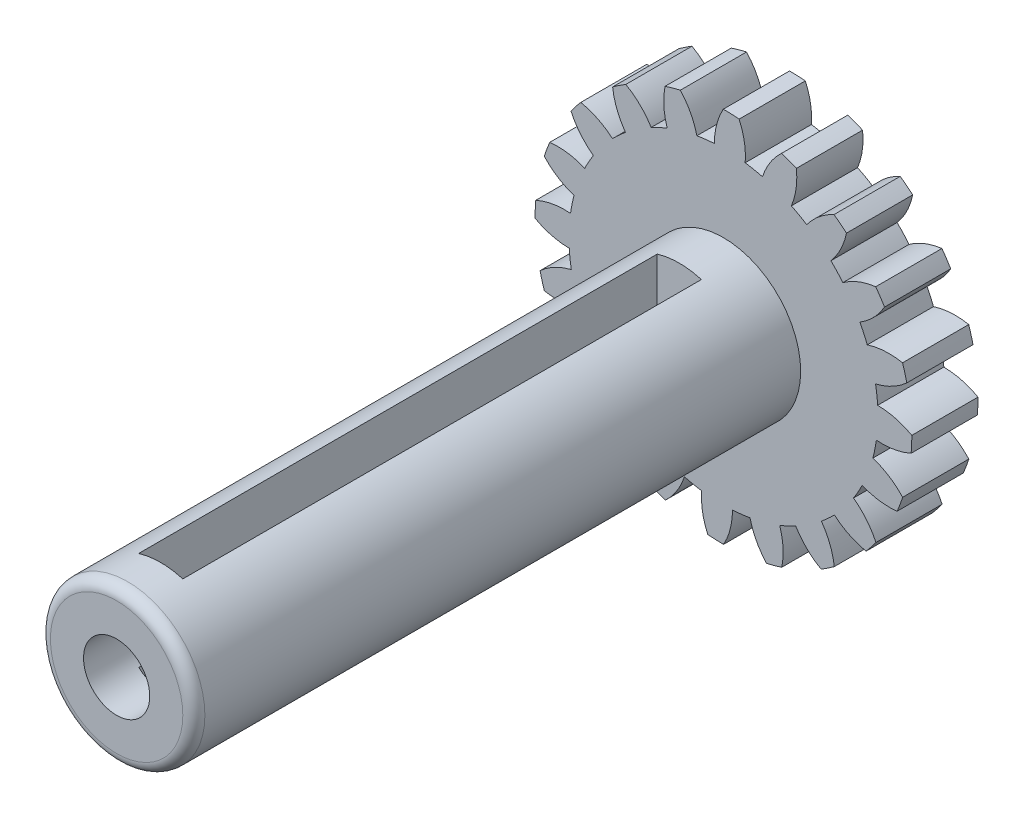
from build123d import *

# Parameters (mm, degrees)
EXTRUDE_4_DEPTH     = 3
SKETCH_5_R          = 3.5
EXTRUDE_6_DEPTH     = 27.5
SKETCH_8_R          = 1.5
CUT_EXTRUDE_1_DEPTH = 10
SKETCH_10_W         = 2
SKETCH_10_H         = 23.5
CUT_EXTRUDE_2_DEPTH = 5
FILLET_1_R          = 0.5


with BuildPart() as part:
    # 草图4 → 凸台-拉伸4 (new body)
    with BuildSketch(Plane.XY):
        with BuildLine():
            ThreePointArc((8.536063079, 0.007574004), (7.787120491, 0.307636704), (6.986931627, 0.410837493))
            ThreePointArc((6.986931627, 0.410837493), (6.952112765, 0.808782481), (6.894647301, 1.204092849))
            ThreePointArc((6.894647301, 1.204092849), (7.649774364, 1.488233206), (8.309831075, 1.95221355))
            ThreePointArc((8.309831075, 1.95221355), (8.220185959, 2.300646222), (8.115937918, 2.644991862))
            ThreePointArc((8.115937918, 2.644991862), (7.310926717, 2.698932461), (6.518011085, 2.549810286))
            ThreePointArc((6.518011085, 2.549810286), (6.361924616, 2.91751884), (6.18511409, 3.275723537))
            ThreePointArc((6.18511409, 3.275723537), (6.815478405, 3.77930417), (7.29985183, 4.424544441))
            ThreePointArc((7.29985183, 4.424544441), (7.106922641, 4.72822174), (6.901368208, 5.023499488))
            ThreePointArc((6.901368208, 5.023499488), (6.119088497, 4.826037904), (5.411062205, 4.439189883))
            ThreePointArc((5.411062205, 4.439189883), (5.148986959, 4.740668128), (4.870138818, 5.026703581))
            ThreePointArc((4.870138818, 5.026703581), (5.314035933, 5.70043051), (5.575312226, 6.463770094))
            ThreePointArc((5.575312226, 6.463770094), (5.297984218, 6.69296597), (5.011244492, 6.910271984))
            ThreePointArc((5.011244492, 6.910271984), (4.328271261, 6.480737132), (3.774440855, 5.894030644))
            ThreePointArc((3.774440855, 5.894030644), (3.432030584, 6.099767788), (3.078440426, 6.285634856))
            ThreePointArc((3.078440426, 6.285634856), (3.292418599, 7.063558994), (3.305022217, 7.870276894))
            ThreePointArc((3.305022217, 7.870276894), (2.970442186, 8.002556058), (2.63058525, 8.12061891))
            ThreePointArc((2.63058525, 8.12061891), (2.113772678, 7.501056656), (1.768350936, 6.77192262))
            ThreePointArc((1.768350936, 6.77192262), (1.379123142, 6.861779679), (0.985402836, 6.929284397))
            ThreePointArc((0.985402836, 6.929284397), (0.948516393, 7.735257109), (0.711213605, 8.506386157))
            ThreePointArc((0.711213605, 8.506386157), (0.352132577, 8.528800203), (-0.007574004, 8.536063079))
            ThreePointArc((-0.007574004, 8.536063079), (-0.307636703, 7.787120491), (-0.410837493, 6.986931627))
            ThreePointArc((-0.410837493, 6.986931627), (-0.808782481, 6.952112765), (-1.204092849, 6.894647301))
            ThreePointArc((-1.204092849, 6.894647301), (-1.488233206, 7.649774364), (-1.95221355, 8.309831075))
            ThreePointArc((-1.95221355, 8.309831075), (-2.300646222, 8.220185959), (-2.644991862, 8.115937918))
            ThreePointArc((-2.644991862, 8.115937918), (-2.698932461, 7.310926717), (-2.549810286, 6.518011085))
            ThreePointArc((-2.549810286, 6.518011085), (-2.91751884, 6.361924616), (-3.275723537, 6.18511409))
            ThreePointArc((-3.275723537, 6.18511409), (-3.77930417, 6.815478405), (-4.424544441, 7.29985183))
            ThreePointArc((-4.424544441, 7.29985183), (-4.72822174, 7.106922641), (-5.023499488, 6.901368208))
            ThreePointArc((-5.023499488, 6.901368208), (-4.826037904, 6.119088497), (-4.439189882, 5.411062205))
            ThreePointArc((-4.439189882, 5.411062205), (-4.740668128, 5.148986959), (-5.026703581, 4.870138818))
            ThreePointArc((-5.026703581, 4.870138818), (-5.70043051, 5.314035933), (-6.463770094, 5.575312226))
            ThreePointArc((-6.463770094, 5.575312226), (-6.69296597, 5.297984218), (-6.910271984, 5.011244492))
            ThreePointArc((-6.910271984, 5.011244492), (-6.480737132, 4.328271262), (-5.894030644, 3.774440855))
            ThreePointArc((-5.894030644, 3.774440855), (-6.099767788, 3.432030584), (-6.285634856, 3.078440426))
            ThreePointArc((-6.285634856, 3.078440426), (-7.063558994, 3.292418599), (-7.870276894, 3.305022217))
            ThreePointArc((-7.870276894, 3.305022217), (-8.002556058, 2.970442186), (-8.12061891, 2.63058525))
            ThreePointArc((-8.12061891, 2.63058525), (-7.501056656, 2.113772678), (-6.77192262, 1.768350936))
            ThreePointArc((-6.77192262, 1.768350936), (-6.861779679, 1.379123142), (-6.929284397, 0.985402836))
            ThreePointArc((-6.929284397, 0.985402836), (-7.735257109, 0.948516393), (-8.506386157, 0.711213605))
            ThreePointArc((-8.506386157, 0.711213605), (-8.528800203, 0.352132577), (-8.536063079, -0.007574004))
            ThreePointArc((-8.536063079, -0.007574004), (-7.787120492, -0.307636703), (-6.986931627, -0.410837493))
            ThreePointArc((-6.986931627, -0.410837493), (-6.952112765, -0.808782481), (-6.894647301, -1.204092849))
            ThreePointArc((-6.894647301, -1.204092849), (-7.649774364, -1.488233206), (-8.309831076, -1.95221355))
            ThreePointArc((-8.309831076, -1.95221355), (-8.220185959, -2.300646222), (-8.115937918, -2.644991862))
            ThreePointArc((-8.115937918, -2.644991862), (-7.310926717, -2.698932461), (-6.518011085, -2.549810286))
            ThreePointArc((-6.518011085, -2.549810286), (-6.361924616, -2.91751884), (-6.18511409, -3.275723537))
            ThreePointArc((-6.18511409, -3.275723537), (-6.815478405, -3.77930417), (-7.29985183, -4.424544441))
            ThreePointArc((-7.29985183, -4.424544441), (-7.106922641, -4.72822174), (-6.901368208, -5.023499488))
            ThreePointArc((-6.901368208, -5.023499488), (-6.119088498, -4.826037904), (-5.411062205, -4.439189883))
            ThreePointArc((-5.411062205, -4.439189883), (-5.148986959, -4.740668128), (-4.870138818, -5.026703582))
            ThreePointArc((-4.870138818, -5.026703582), (-5.314035933, -5.70043051), (-5.575312227, -6.463770094))
            ThreePointArc((-5.575312227, -6.463770094), (-5.297984218, -6.69296597), (-5.011244492, -6.910271984))
            ThreePointArc((-5.011244492, -6.910271984), (-4.328271262, -6.480737132), (-3.774440855, -5.894030644))
            ThreePointArc((-3.774440855, -5.894030644), (-3.432030584, -6.099767789), (-3.078440426, -6.285634856))
            ThreePointArc((-3.078440426, -6.285634856), (-3.292418599, -7.063558994), (-3.305022217, -7.870276894))
            ThreePointArc((-3.305022217, -7.870276894), (-2.970442186, -8.002556058), (-2.63058525, -8.12061891))
            ThreePointArc((-2.63058525, -8.12061891), (-2.113772678, -7.501056656), (-1.768350936, -6.77192262))
            ThreePointArc((-1.768350936, -6.77192262), (-1.379123142, -6.861779679), (-0.985402836, -6.929284397))
            ThreePointArc((-0.985402836, -6.929284397), (-0.948516393, -7.735257109), (-0.711213605, -8.506386157))
            ThreePointArc((-0.711213605, -8.506386157), (-0.352132577, -8.528800203), (0.007574004, -8.536063079))
            ThreePointArc((0.007574004, -8.536063079), (0.307636704, -7.787120491), (0.410837493, -6.986931627))
            ThreePointArc((0.410837493, -6.986931627), (0.808782481, -6.952112765), (1.204092849, -6.894647301))
            ThreePointArc((1.204092849, -6.894647301), (1.488233206, -7.649774364), (1.95221355, -8.309831075))
            ThreePointArc((1.95221355, -8.309831075), (2.300646222, -8.220185959), (2.644991862, -8.115937918))
            ThreePointArc((2.644991862, -8.115937918), (2.698932461, -7.310926717), (2.549810286, -6.518011085))
            ThreePointArc((2.549810286, -6.518011085), (2.91751884, -6.361924616), (3.275723537, -6.18511409))
            ThreePointArc((3.275723537, -6.18511409), (3.77930417, -6.815478405), (4.424544441, -7.29985183))
            ThreePointArc((4.424544441, -7.29985183), (4.72822174, -7.106922641), (5.023499488, -6.901368208))
            ThreePointArc((5.023499488, -6.901368208), (4.826037904, -6.119088497), (4.439189883, -5.411062205))
            ThreePointArc((4.439189883, -5.411062205), (4.740668128, -5.148986959), (5.026703582, -4.870138818))
            ThreePointArc((5.026703582, -4.870138818), (5.70043051, -5.314035933), (6.463770094, -5.575312226))
            ThreePointArc((6.463770094, -5.575312226), (6.69296597, -5.297984218), (6.910271984, -5.011244492))
            ThreePointArc((6.910271984, -5.011244492), (6.480737132, -4.328271261), (5.894030644, -3.774440855))
            ThreePointArc((5.894030644, -3.774440855), (6.099767788, -3.432030584), (6.285634856, -3.078440425))
            ThreePointArc((6.285634856, -3.078440425), (7.063558994, -3.292418599), (7.870276894, -3.305022217))
            ThreePointArc((7.870276894, -3.305022217), (8.002556058, -2.970442186), (8.12061891, -2.63058525))
            ThreePointArc((8.12061891, -2.63058525), (7.501056656, -2.113772678), (6.77192262, -1.768350936))
            ThreePointArc((6.77192262, -1.768350936), (6.861779679, -1.379123142), (6.929284397, -0.985402836))
            ThreePointArc((6.929284397, -0.985402836), (7.735257109, -0.948516393), (8.506386157, -0.711213605))
            ThreePointArc((8.506386157, -0.711213605), (8.528643141, -0.355916321), (8.536066439, 0))
            ThreePointArc((8.536066439, 0), (8.536065599, 0.003787002), (8.536063079, 0.007574004))
        make_face()
    extrude(amount=EXTRUDE_4_DEPTH)

    # 草图5 → 凸台-拉伸6 (add)
    with BuildSketch(Plane.XY.offset(3)):
        Circle(SKETCH_5_R)
    extrude(amount=EXTRUDE_6_DEPTH)

    # 草图8 → 切除-拉伸1 (cut)
    with BuildSketch(Plane.XY.offset(30.5)):
        Circle(SKETCH_8_R)
    extrude(amount=-CUT_EXTRUDE_1_DEPTH, mode=Mode.SUBTRACT)

    # 草图10 → 切除-拉伸2 (cut, symmetric)
    with BuildSketch(Plane(origin=(0, 0, 0), x_dir=(1, 0, 0), z_dir=(0, 1, 0))):
        with Locations((0, -16.75)):
            Rectangle(SKETCH_10_W, SKETCH_10_H)
    extrude(amount=CUT_EXTRUDE_2_DEPTH, both=True, mode=Mode.SUBTRACT)

    # 圆角1
    fillet_1_edges = [part.edges().sort_by_distance(p)[0] for p in [
        (-3.5, 0, 30.5),
    ]]
    fillet(fillet_1_edges, radius=FILLET_1_R)


solid = part.part
